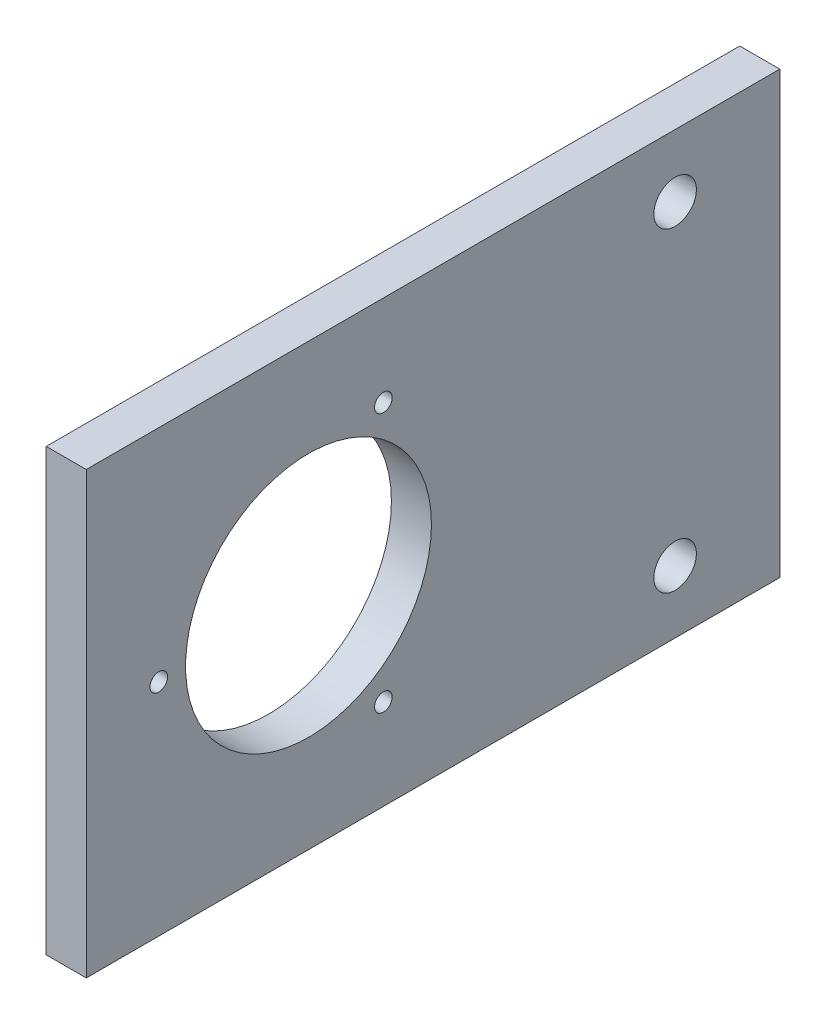
from build123d import *

# Parameters (mm, degrees)
SKETCH1_W           = 69.85
SKETCH1_H           = 110
SKETCH1_R           = 19.5
SKETCH1_R_2         = 3.37312
SKETCH1_R_3         = 1.4
BOSS_EXTRUDE1_DEPTH = 6.35


with BuildPart() as part:
    # Sketch1 → Boss-Extrude1 (new body)
    with BuildSketch(Plane.YZ):
        Rectangle(SKETCH1_W, SKETCH1_H)
        with Locations((0, 19.75)):
            Circle(SKETCH1_R, mode=Mode.SUBTRACT)
        with Locations((-25, -38.4)):
            Circle(SKETCH1_R_2, mode=Mode.SUBTRACT)
        with Locations((25, -38.4)):
            Circle(SKETCH1_R_2, mode=Mode.SUBTRACT)
        with Locations((0, 43.5)):
            Circle(SKETCH1_R_3, mode=Mode.SUBTRACT)
        with Locations((20.56810334, 7.875)):
            Circle(SKETCH1_R_3, mode=Mode.SUBTRACT)
        with Locations((-20.56810334, 7.875)):
            Circle(SKETCH1_R_3, mode=Mode.SUBTRACT)
    extrude(amount=BOSS_EXTRUDE1_DEPTH)


solid = part.part
